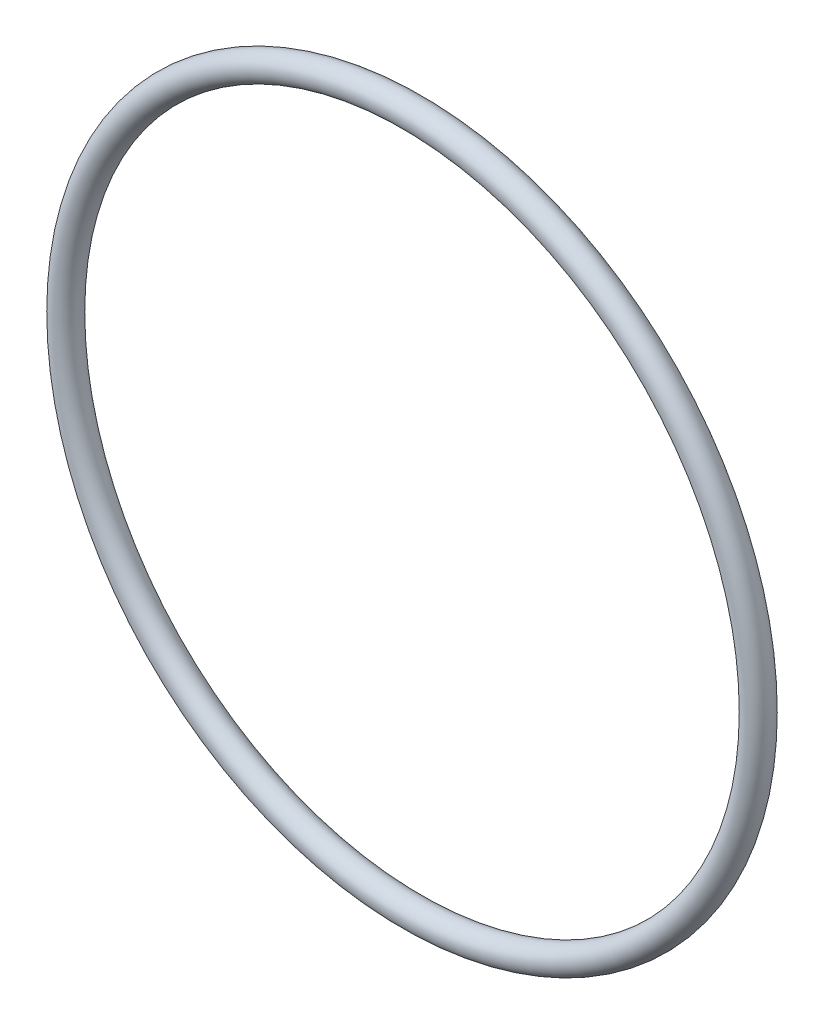
from build123d import *

# Parameters (mm, degrees)
SKETCH1_R = 1.3081


with BuildPart() as part:
    # Sketch1 → Revolve1 (revolve)
    with BuildSketch(Plane(origin=(0, 0, 0), x_dir=(0, -1, 0), z_dir=(1, 0, 0))):
        with Locations((33.6931, 0)):
            Circle(SKETCH1_R)
    revolve(axis=Axis((0, 0, 0), (0, 0, -1)))


solid = part.part
